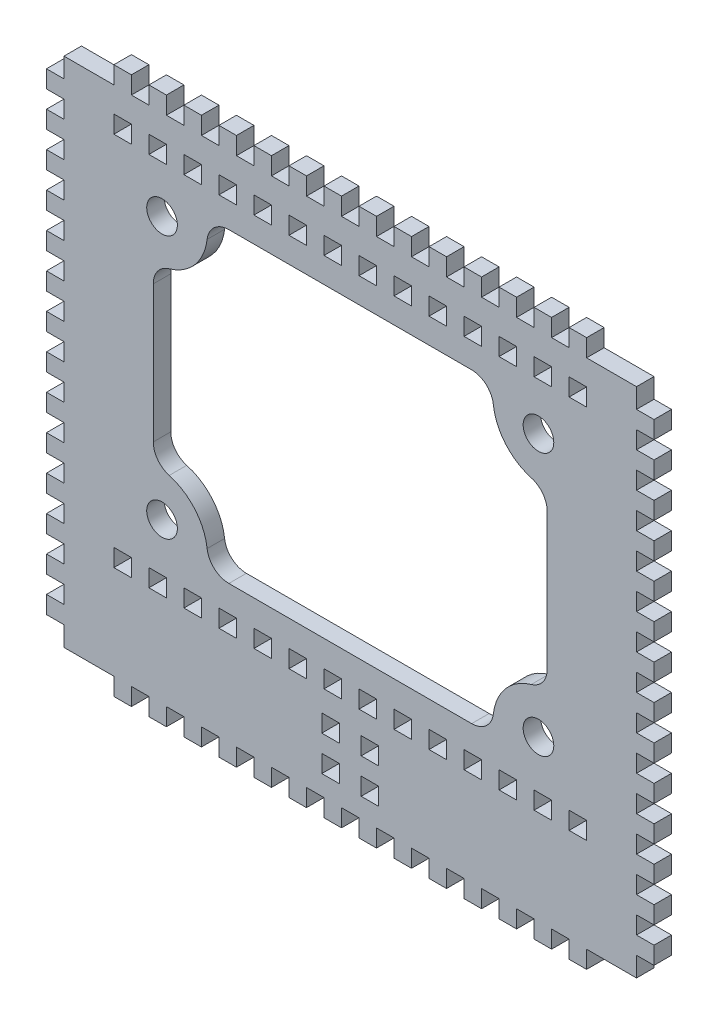
from build123d import *

# Parameters (mm, degrees)
SKETCH1_R           = 3.5
BOSS_EXTRUDE1_DEPTH = 4
SKETCH3_W           = 4
SKETCH3_H           = 4
CUT_EXTRUDE2_DEPTH  = 4
FILLET1_R           = 5
FILLET2_R           = 5
FILLET3_R           = 5
FILLET4_R           = 5
FILLET5_R           = 5
FILLET6_R           = 5
FILLET7_R           = 5
FILLET8_R           = 5
SKETCH5_W           = 4
SKETCH5_H           = 4
BOSS_EXTRUDE2_DEPTH = 4


with BuildPart() as part:
    # Sketch1 → Boss-Extrude1 (new body)
    with BuildSketch(Plane.XY):
        Polygon((-65.4, -66.5), (-65.4, -62), (-69.4, -62), (-69.4, -58), (-65.4, -58), (-65.4, -54), (-69.4, -54), (-69.4, -50), (-65.4, -50), (-65.4, -46), (-69.4, -46), (-69.4, -42), (-65.4, -42), (-65.4, -38), (-69.4, -38), (-69.4, -34), (-65.4, -34), (-65.4, -30), (-69.4, -30), (-69.4, -26), (-65.4, -26), (-65.4, -22), (-69.4, -22), (-69.4, -18), (-65.4, -18), (-65.4, -14), (-69.4, -14), (-69.4, -10), (-65.4, -10), (-65.4, -6), (-69.4, -6), (-69.4, -2), (-65.4, -2), (-65.4, 2), (-69.4, 2), (-69.4, 6), (-65.4, 6), (-65.4, 10), (-69.4, 10), (-69.4, 14), (-65.4, 14), (-65.4, 18), (-69.4, 18), (-69.4, 22), (-65.4, 22), (-65.4, 26), (-69.4, 26), (-69.4, 30), (-65.4, 30), (-65.4, 34), (-69.4, 34), (-69.4, 38), (-65.4, 38), (-65.4, 42), (-69.4, 42), (-69.4, 46), (-65.4, 46), (-65.4, 50.5), (65.4, 50.5), (65.4, 46), (69.4, 46), (69.4, 42), (65.4, 42), (65.4, 38), (69.4, 38), (69.4, 34), (65.4, 34), (65.4, 30), (69.4, 30), (69.4, 26), (65.4, 26), (65.4, 22), (69.4, 22), (69.4, 18), (65.4, 18), (65.4, 14), (69.4, 14), (69.4, 10), (65.4, 10), (65.4, 6), (69.4, 6), (69.4, 2), (65.4, 2), (65.4, -2), (69.4, -2), (69.4, -6), (65.4, -6), (65.4, -10), (69.4, -10), (69.4, -14), (65.4, -14), (65.4, -18), (69.4, -18), (69.4, -22), (65.4, -22), (65.4, -26), (69.4, -26), (69.4, -30), (65.4, -30), (65.4, -34), (69.4, -34), (69.4, -38), (65.4, -38), (65.4, -42), (69.4, -42), (69.4, -46), (65.4, -46), (65.4, -50), (69.4, -50), (69.4, -54), (65.4, -54), (65.4, -58), (69.4, -58), (69.4, -62), (65.4, -62), (65.4, -66.5), align=None)
        with Locations((-43, 30)):
            Circle(SKETCH1_R, mode=Mode.SUBTRACT)
        with Locations((43, 30)):
            Circle(SKETCH1_R, mode=Mode.SUBTRACT)
        with Locations((43, -30)):
            Circle(SKETCH1_R, mode=Mode.SUBTRACT)
        with Locations((-43, -30)):
            Circle(SKETCH1_R, mode=Mode.SUBTRACT)
        with BuildLine():
            Line((-45, -20), (-45, 20))
            ThreePointArc((-45, 20), (-35.246947165, 24.497557732), (-33, 35))
            Line((-33, 35), (33, 35))
            ThreePointArc((33, 35), (35.246947165, 24.497557732), (45, 20))
            Line((45, 20), (45, -20))
            ThreePointArc((45, -20), (35.246947165, -24.497557732), (33, -35))
            Line((33, -35), (-33, -35))
            ThreePointArc((-33, -35), (-35.246947165, -24.497557732), (-45, -20))
        make_face(mode=Mode.SUBTRACT)
    extrude(amount=BOSS_EXTRUDE1_DEPTH)

    # Sketch3 → Cut-Extrude2 (cut)
    with BuildSketch(Plane.XY.offset(4)):
        with Locations((-52, -43)):
            Rectangle(SKETCH3_W, SKETCH3_H)
        with Locations((44, -43)):
            Rectangle(SKETCH3_W, SKETCH3_H)
        with Locations((-4.5, -52)):
            Rectangle(SKETCH3_W, SKETCH3_H)
        with Locations((36, -43)):
            Rectangle(SKETCH3_W, SKETCH3_H)
        with Locations((28, -43)):
            Rectangle(SKETCH3_W, SKETCH3_H)
        with Locations((20, -43)):
            Rectangle(SKETCH3_W, SKETCH3_H)
        with Locations((12, -43)):
            Rectangle(SKETCH3_W, SKETCH3_H)
        with Locations((4, -43)):
            Rectangle(SKETCH3_W, SKETCH3_H)
        with Locations((52, -43)):
            Rectangle(SKETCH3_W, SKETCH3_H)
        with Locations((-12, 42.75)):
            Rectangle(SKETCH3_W, SKETCH3_H)
        with Locations((-4, 42.75)):
            Rectangle(SKETCH3_W, SKETCH3_H)
        with Locations((-20, 42.75)):
            Rectangle(SKETCH3_W, SKETCH3_H)
        with Locations((-28, 42.75)):
            Rectangle(SKETCH3_W, SKETCH3_H)
        with Locations((-36, 42.75)):
            Rectangle(SKETCH3_W, SKETCH3_H)
        with Locations((-12, -43)):
            Rectangle(SKETCH3_W, SKETCH3_H)
        with Locations((-4, -43)):
            Rectangle(SKETCH3_W, SKETCH3_H)
        with Locations((-20, -43)):
            Rectangle(SKETCH3_W, SKETCH3_H)
        with Locations((-28, -43)):
            Rectangle(SKETCH3_W, SKETCH3_H)
        with Locations((-36, -43)):
            Rectangle(SKETCH3_W, SKETCH3_H)
        with Locations((-44, -43)):
            Rectangle(SKETCH3_W, SKETCH3_H)
        with Locations((-44, 42.75)):
            Rectangle(SKETCH3_W, SKETCH3_H)
        with Locations((-52, 42.75)):
            Rectangle(SKETCH3_W, SKETCH3_H)
        with Locations((52, 42.75)):
            Rectangle(SKETCH3_W, SKETCH3_H)
        with Locations((44, 42.75)):
            Rectangle(SKETCH3_W, SKETCH3_H)
        with Locations((36, 42.75)):
            Rectangle(SKETCH3_W, SKETCH3_H)
        with Locations((28, 42.75)):
            Rectangle(SKETCH3_W, SKETCH3_H)
        with Locations((20, 42.75)):
            Rectangle(SKETCH3_W, SKETCH3_H)
        with Locations((12, 42.75)):
            Rectangle(SKETCH3_W, SKETCH3_H)
        with Locations((4, 42.75)):
            Rectangle(SKETCH3_W, SKETCH3_H)
        with Locations((4.5, -52)):
            Rectangle(SKETCH3_W, SKETCH3_H)
        with Locations((-4.5, -60)):
            Rectangle(SKETCH3_W, SKETCH3_H)
        with Locations((4.5, -60)):
            Rectangle(SKETCH3_W, SKETCH3_H)
    extrude(amount=-CUT_EXTRUDE2_DEPTH, mode=Mode.SUBTRACT)

    # Fillet1
    fillet1_edges = [part.edges().sort_by_distance(p)[0] for p in [
        (-45, 20, 2),
    ]]
    fillet(fillet1_edges, radius=FILLET1_R)

    # Fillet2
    fillet2_edges = [part.edges().sort_by_distance(p)[0] for p in [
        (-33, 35, 2),
    ]]
    fillet(fillet2_edges, radius=FILLET2_R)

    # Fillet3
    fillet3_edges = [part.edges().sort_by_distance(p)[0] for p in [
        (33, 35, 2),
    ]]
    fillet(fillet3_edges, radius=FILLET3_R)

    # Fillet4
    fillet4_edges = [part.edges().sort_by_distance(p)[0] for p in [
        (45, 20, 2),
    ]]
    fillet(fillet4_edges, radius=FILLET4_R)

    # Fillet5
    fillet5_edges = [part.edges().sort_by_distance(p)[0] for p in [
        (33, -35, 2),
    ]]
    fillet(fillet5_edges, radius=FILLET5_R)

    # Fillet6
    fillet6_edges = [part.edges().sort_by_distance(p)[0] for p in [
        (45, -20, 2),
    ]]
    fillet(fillet6_edges, radius=FILLET6_R)

    # Fillet7
    fillet7_edges = [part.edges().sort_by_distance(p)[0] for p in [
        (-45, -20, 2),
    ]]
    fillet(fillet7_edges, radius=FILLET7_R)

    # Fillet8
    fillet8_edges = [part.edges().sort_by_distance(p)[0] for p in [
        (-33, -35, 2),
    ]]
    fillet(fillet8_edges, radius=FILLET8_R)

    # Sketch5 → Boss-Extrude2 (add)
    with BuildSketch(Plane.XY.offset(4)):
        with Locations((-4, 52.5)):
            Rectangle(SKETCH5_W, SKETCH5_H)
        with Locations((-12, 52.5)):
            Rectangle(SKETCH5_W, SKETCH5_H)
        with Locations((-20, 52.5)):
            Rectangle(SKETCH5_W, SKETCH5_H)
        with Locations((-28, 52.5)):
            Rectangle(SKETCH5_W, SKETCH5_H)
        with Locations((-36, 52.5)):
            Rectangle(SKETCH5_W, SKETCH5_H)
        with Locations((-44, 52.5)):
            Rectangle(SKETCH5_W, SKETCH5_H)
        with Locations((-52, 52.5)):
            Rectangle(SKETCH5_W, SKETCH5_H)
        with Locations((52, 52.5)):
            Rectangle(SKETCH5_W, SKETCH5_H)
        with Locations((44, 52.5)):
            Rectangle(SKETCH5_W, SKETCH5_H)
        with Locations((36, 52.5)):
            Rectangle(SKETCH5_W, SKETCH5_H)
        with Locations((28, 52.5)):
            Rectangle(SKETCH5_W, SKETCH5_H)
        with Locations((20, 52.5)):
            Rectangle(SKETCH5_W, SKETCH5_H)
        with Locations((12, 52.5)):
            Rectangle(SKETCH5_W, SKETCH5_H)
        with Locations((4, 52.5)):
            Rectangle(SKETCH5_W, SKETCH5_H)
        with Locations((4, -68.5)):
            Rectangle(SKETCH5_W, SKETCH5_H)
        with Locations((12, -68.5)):
            Rectangle(SKETCH5_W, SKETCH5_H)
        with Locations((20, -68.5)):
            Rectangle(SKETCH5_W, SKETCH5_H)
        with Locations((28, -68.5)):
            Rectangle(SKETCH5_W, SKETCH5_H)
        with Locations((36, -68.5)):
            Rectangle(SKETCH5_W, SKETCH5_H)
        with Locations((44, -68.5)):
            Rectangle(SKETCH5_W, SKETCH5_H)
        with Locations((52, -68.5)):
            Rectangle(SKETCH5_W, SKETCH5_H)
        with Locations((-52, -68.5)):
            Rectangle(SKETCH5_W, SKETCH5_H)
        with Locations((-44, -68.5)):
            Rectangle(SKETCH5_W, SKETCH5_H)
        with Locations((-36, -68.5)):
            Rectangle(SKETCH5_W, SKETCH5_H)
        with Locations((-28, -68.5)):
            Rectangle(SKETCH5_W, SKETCH5_H)
        with Locations((-20, -68.5)):
            Rectangle(SKETCH5_W, SKETCH5_H)
        with Locations((-12, -68.5)):
            Rectangle(SKETCH5_W, SKETCH5_H)
        with Locations((-4, -68.5)):
            Rectangle(SKETCH5_W, SKETCH5_H)
    extrude(amount=-BOSS_EXTRUDE2_DEPTH)


solid = part.part
